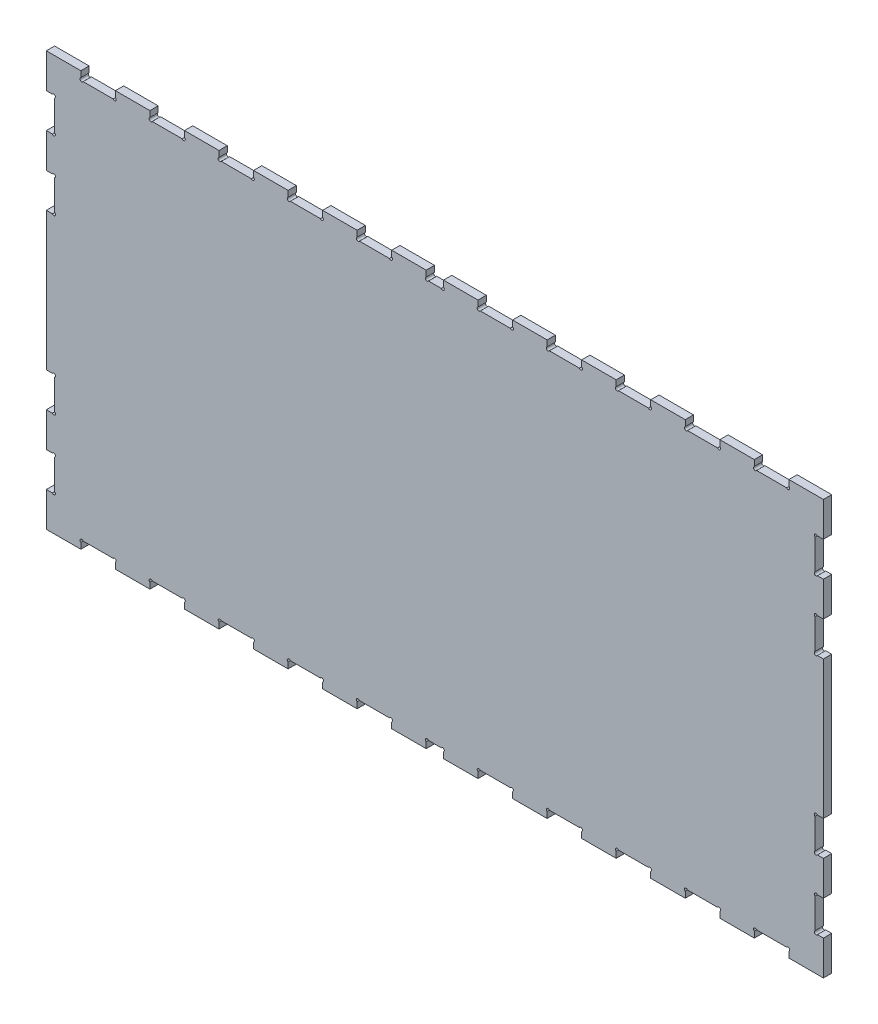
from build123d import *

# Parameters (mm, degrees)
BOSS_EXTRUDE1_DEPTH = 12


with BuildPart() as part:
    # Sketch1 → Boss-Extrude1 (new body)
    with BuildSketch(Plane.XY):
        with BuildLine():
            Line((718.789964832, 153.631186924), (668.789964832, 153.631186924))
            Line((668.789964832, 153.631186924), (668.789964832, 144.909647893))
            ThreePointArc((668.789964832, 144.909647893), (669.287021106, 141.13413065), (665.511503862, 141.631186924))
            Line((665.511503862, 141.631186924), (622.068425801, 141.631186924))
            ThreePointArc((622.068425801, 141.631186924), (618.292908557, 141.13413065), (618.789964832, 144.909647893))
            Line((618.789964832, 144.909647893), (618.789964832, 153.631186924))
            Line((618.789964832, 153.631186924), (568.789964832, 153.631186924))
            Line((568.789964832, 153.631186924), (568.789964832, 144.909647893))
            ThreePointArc((568.789964832, 144.909647893), (569.287021106, 141.13413065), (565.511503862, 141.631186924))
            Line((565.511503862, 141.631186924), (522.068425801, 141.631186924))
            ThreePointArc((522.068425801, 141.631186924), (518.292908557, 141.13413065), (518.789964832, 144.909647893))
            Line((518.789964832, 144.909647893), (518.789964832, 153.631186924))
            Line((518.789964832, 153.631186924), (468.789964832, 153.631186924))
            Line((468.789964832, 153.631186924), (468.789964832, 144.909647893))
            ThreePointArc((468.789964832, 144.909647893), (469.287021106, 141.13413065), (465.511503862, 141.631186924))
            Line((465.511503862, 141.631186924), (422.068425801, 141.631186924))
            ThreePointArc((422.068425801, 141.631186924), (418.292908557, 141.13413065), (418.789964832, 144.909647893))
            Line((418.789964832, 144.909647893), (418.789964832, 153.631186924))
            Line((418.789964832, 153.631186924), (368.789964832, 153.631186924))
            Line((368.789964832, 153.631186924), (368.789964832, 144.909647893))
            ThreePointArc((368.789964832, 144.909647893), (369.287021106, 141.13413065), (365.511503862, 141.631186924))
            Line((365.511503862, 141.631186924), (322.068425801, 141.631186924))
            ThreePointArc((322.068425801, 141.631186924), (318.292908557, 141.13413065), (318.789964832, 144.909647893))
            Line((318.789964832, 144.909647893), (318.789964832, 153.631186924))
            Line((318.789964832, 153.631186924), (268.789964832, 153.631186924))
            Line((268.789964832, 153.631186924), (268.789964832, 144.909647893))
            ThreePointArc((268.789964832, 144.909647893), (269.287021106, 141.13413065), (265.511503862, 141.631186924))
            Line((265.511503862, 141.631186924), (222.068425801, 141.631186924))
            ThreePointArc((222.068425801, 141.631186924), (218.292908557, 141.13413065), (218.789964832, 144.909647893))
            Line((218.789964832, 144.909647893), (218.789964832, 153.631186924))
            Line((218.789964832, 153.631186924), (168.789964832, 153.631186924))
            Line((168.789964832, 153.631186924), (168.789964832, 144.909647893))
            ThreePointArc((168.789964832, 144.909647893), (169.287021106, 141.13413065), (165.511503862, 141.631186924))
            Line((165.511503862, 141.631186924), (147.068425801, 141.631186924))
            ThreePointArc((147.068425801, 141.631186924), (143.292908557, 141.13413065), (143.789964832, 144.909647893))
            Line((143.789964832, 144.909647893), (143.789964832, 153.631186924))
            Line((143.789964832, 153.631186924), (93.789964832, 153.631186924))
            Line((93.789964832, 153.631186924), (93.789964832, 144.909647893))
            ThreePointArc((93.789964832, 144.909647893), (94.287021106, 141.13413065), (90.511503862, 141.631186924))
            Line((90.511503862, 141.631186924), (47.068425801, 141.631186924))
            ThreePointArc((47.068425801, 141.631186924), (43.292908557, 141.13413065), (43.789964832, 144.909647893))
            Line((43.789964832, 144.909647893), (43.789964832, 153.631186924))
            Line((43.789964832, 153.631186924), (-6.210035168, 153.631186924))
            Line((-6.210035168, 153.631186924), (-6.210035168, 144.909647893))
            ThreePointArc((-6.210035168, 144.909647893), (-5.712978894, 141.13413065), (-9.488496138, 141.631186924))
            Line((-9.488496138, 141.631186924), (-52.931574199, 141.631186924))
            ThreePointArc((-52.931574199, 141.631186924), (-56.707091443, 141.13413065), (-56.210035168, 144.909647893))
            Line((-56.210035168, 144.909647893), (-56.210035168, 153.631186924))
            Line((-56.210035168, 153.631186924), (-106.210035168, 153.631186924))
            Line((-106.210035168, 153.631186924), (-106.210035168, 144.909647893))
            ThreePointArc((-106.210035168, 144.909647893), (-105.712978894, 141.13413065), (-109.488496138, 141.631186924))
            Line((-109.488496138, 141.631186924), (-152.931574199, 141.631186924))
            ThreePointArc((-152.931574199, 141.631186924), (-156.707091443, 141.13413065), (-156.210035168, 144.909647893))
            Line((-156.210035168, 144.909647893), (-156.210035168, 153.631186924))
            Line((-156.210035168, 153.631186924), (-206.210035168, 153.631186924))
            Line((-206.210035168, 153.631186924), (-206.210035168, 144.909647893))
            ThreePointArc((-206.210035168, 144.909647893), (-205.712978894, 141.13413065), (-209.488496138, 141.631186924))
            Line((-209.488496138, 141.631186924), (-252.931574199, 141.631186924))
            ThreePointArc((-252.931574199, 141.631186924), (-256.707091443, 141.13413065), (-256.210035168, 144.909647893))
            Line((-256.210035168, 144.909647893), (-256.210035168, 153.631186924))
            Line((-256.210035168, 153.631186924), (-306.210035168, 153.631186924))
            Line((-306.210035168, 153.631186924), (-306.210035168, 144.909647893))
            ThreePointArc((-306.210035168, 144.909647893), (-305.712978894, 141.13413065), (-309.488496138, 141.631186924))
            Line((-309.488496138, 141.631186924), (-352.931574199, 141.631186924))
            ThreePointArc((-352.931574199, 141.631186924), (-356.707091443, 141.13413065), (-356.210035168, 144.909647893))
            Line((-356.210035168, 144.909647893), (-356.210035168, 153.631186924))
            Line((-356.210035168, 153.631186924), (-406.210035168, 153.631186924))
            Line((-406.210035168, 153.631186924), (-406.210035168, 103.631186924))
            Line((-406.210035168, 103.631186924), (-397.488496138, 103.631186924))
            ThreePointArc((-397.488496138, 103.631186924), (-393.712978894, 104.128243199), (-394.210035168, 100.352725955))
            Line((-394.210035168, 100.352725955), (-394.210035168, 56.909647893))
            ThreePointArc((-394.210035168, 56.909647893), (-393.712978894, 53.13413065), (-397.488496138, 53.631186924))
            Line((-397.488496138, 53.631186924), (-406.210035168, 53.631186924))
            Line((-406.210035168, 53.631186924), (-406.210035168, 3.631186924))
            Line((-406.210035168, 3.631186924), (-397.488496138, 3.631186924))
            ThreePointArc((-397.488496138, 3.631186924), (-393.712978894, 4.128243199), (-394.210035168, 0.352725955))
            Line((-394.210035168, 0.352725955), (-394.210035168, -43.090352107))
            ThreePointArc((-394.210035168, -43.090352107), (-393.712978894, -46.86586935), (-397.488496138, -46.368813076))
            Line((-397.488496138, -46.368813076), (-406.210035168, -46.368813076))
            Line((-406.210035168, -46.368813076), (-406.210035168, -246.368813076))
            Line((-406.210035168, -246.368813076), (-397.488496138, -246.368813076))
            ThreePointArc((-397.488496138, -246.368813076), (-393.712978894, -245.871756801), (-394.210035168, -249.647274045))
            Line((-394.210035168, -249.647274045), (-394.210035168, -293.090352107))
            ThreePointArc((-394.210035168, -293.090352107), (-393.712978894, -296.86586935), (-397.488496138, -296.368813076))
            Line((-397.488496138, -296.368813076), (-406.210035168, -296.368813076))
            Line((-406.210035168, -296.368813076), (-406.210035168, -346.368813076))
            Line((-406.210035168, -346.368813076), (-397.488496138, -346.368813076))
            ThreePointArc((-397.488496138, -346.368813076), (-393.712978894, -345.871756801), (-394.210035168, -349.647274045))
            Line((-394.210035168, -349.647274045), (-394.210035168, -393.090352107))
            ThreePointArc((-394.210035168, -393.090352107), (-393.712978894, -396.86586935), (-397.488496138, -396.368813076))
            Line((-397.488496138, -396.368813076), (-406.210035168, -396.368813076))
            Line((-406.210035168, -396.368813076), (-406.210035168, -446.368813076))
            Line((-406.210035168, -446.368813076), (-356.210035168, -446.368813076))
            Line((-356.210035168, -446.368813076), (-356.210035168, -437.647274045))
            ThreePointArc((-356.210035168, -437.647274045), (-356.707091443, -433.871756801), (-352.931574199, -434.368813076))
            Line((-352.931574199, -434.368813076), (-309.488496138, -434.368813076))
            ThreePointArc((-309.488496138, -434.368813076), (-305.712978894, -433.871756801), (-306.210035168, -437.647274045))
            Line((-306.210035168, -437.647274045), (-306.210035168, -446.368813076))
            Line((-306.210035168, -446.368813076), (-256.210035168, -446.368813076))
            Line((-256.210035168, -446.368813076), (-256.210035168, -437.647274045))
            ThreePointArc((-256.210035168, -437.647274045), (-256.707091443, -433.871756801), (-252.931574199, -434.368813076))
            Line((-252.931574199, -434.368813076), (-209.488496138, -434.368813076))
            ThreePointArc((-209.488496138, -434.368813076), (-205.712978894, -433.871756801), (-206.210035168, -437.647274045))
            Line((-206.210035168, -437.647274045), (-206.210035168, -446.368813076))
            Line((-206.210035168, -446.368813076), (-156.210035168, -446.368813076))
            Line((-156.210035168, -446.368813076), (-156.210035168, -437.647274045))
            ThreePointArc((-156.210035168, -437.647274045), (-156.707091443, -433.871756801), (-152.931574199, -434.368813076))
            Line((-152.931574199, -434.368813076), (-109.488496138, -434.368813076))
            ThreePointArc((-109.488496138, -434.368813076), (-105.712978894, -433.871756801), (-106.210035168, -437.647274045))
            Line((-106.210035168, -437.647274045), (-106.210035168, -446.368813076))
            Line((-106.210035168, -446.368813076), (-56.210035168, -446.368813076))
            Line((-56.210035168, -446.368813076), (-56.210035168, -437.647274045))
            ThreePointArc((-56.210035168, -437.647274045), (-56.707091443, -433.871756801), (-52.931574199, -434.368813076))
            Line((-52.931574199, -434.368813076), (-9.488496138, -434.368813076))
            ThreePointArc((-9.488496138, -434.368813076), (-5.712978894, -433.871756801), (-6.210035168, -437.647274045))
            Line((-6.210035168, -437.647274045), (-6.210035168, -446.368813076))
            Line((-6.210035168, -446.368813076), (43.789964832, -446.368813076))
            Line((43.789964832, -446.368813076), (43.789964832, -437.647274045))
            ThreePointArc((43.789964832, -437.647274045), (43.292908557, -433.871756801), (47.068425801, -434.368813076))
            Line((47.068425801, -434.368813076), (90.511503862, -434.368813076))
            ThreePointArc((90.511503862, -434.368813076), (94.287021106, -433.871756801), (93.789964832, -437.647274045))
            Line((93.789964832, -437.647274045), (93.789964832, -446.368813076))
            Line((93.789964832, -446.368813076), (143.789964832, -446.368813076))
            Line((143.789964832, -446.368813076), (143.789964832, -437.647274045))
            ThreePointArc((143.789964832, -437.647274045), (143.292908557, -433.871756801), (147.068425801, -434.368813076))
            Line((147.068425801, -434.368813076), (165.511503862, -434.368813076))
            ThreePointArc((165.511503862, -434.368813076), (169.287021106, -433.871756801), (168.789964832, -437.647274045))
            Line((168.789964832, -437.647274045), (168.789964832, -446.368813076))
            Line((168.789964832, -446.368813076), (218.789964832, -446.368813076))
            Line((218.789964832, -446.368813076), (218.789964832, -437.647274045))
            ThreePointArc((218.789964832, -437.647274045), (218.292908557, -433.871756801), (222.068425801, -434.368813076))
            Line((222.068425801, -434.368813076), (265.511503862, -434.368813076))
            ThreePointArc((265.511503862, -434.368813076), (269.287021106, -433.871756801), (268.789964832, -437.647274045))
            Line((268.789964832, -437.647274045), (268.789964832, -446.368813076))
            Line((268.789964832, -446.368813076), (318.789964832, -446.368813076))
            Line((318.789964832, -446.368813076), (318.789964832, -437.647274045))
            ThreePointArc((318.789964832, -437.647274045), (318.292908557, -433.871756801), (322.068425801, -434.368813076))
            Line((322.068425801, -434.368813076), (365.511503862, -434.368813076))
            ThreePointArc((365.511503862, -434.368813076), (369.287021106, -433.871756801), (368.789964832, -437.647274045))
            Line((368.789964832, -437.647274045), (368.789964832, -446.368813076))
            Line((368.789964832, -446.368813076), (418.789964832, -446.368813076))
            Line((418.789964832, -446.368813076), (418.789964832, -437.647274045))
            ThreePointArc((418.789964832, -437.647274045), (418.292908557, -433.871756801), (422.068425801, -434.368813076))
            Line((422.068425801, -434.368813076), (465.511503862, -434.368813076))
            ThreePointArc((465.511503862, -434.368813076), (469.287021106, -433.871756801), (468.789964832, -437.647274045))
            Line((468.789964832, -437.647274045), (468.789964832, -446.368813076))
            Line((468.789964832, -446.368813076), (518.789964832, -446.368813076))
            Line((518.789964832, -446.368813076), (518.789964832, -437.647274045))
            ThreePointArc((518.789964832, -437.647274045), (518.292908557, -433.871756801), (522.068425801, -434.368813076))
            Line((522.068425801, -434.368813076), (565.511503862, -434.368813076))
            ThreePointArc((565.511503862, -434.368813076), (569.287021106, -433.871756801), (568.789964832, -437.647274045))
            Line((568.789964832, -437.647274045), (568.789964832, -446.368813076))
            Line((568.789964832, -446.368813076), (618.789964832, -446.368813076))
            Line((618.789964832, -446.368813076), (618.789964832, -437.647274045))
            ThreePointArc((618.789964832, -437.647274045), (618.292908557, -433.871756801), (622.068425801, -434.368813076))
            Line((622.068425801, -434.368813076), (665.511503862, -434.368813076))
            ThreePointArc((665.511503862, -434.368813076), (669.287021106, -433.871756801), (668.789964832, -437.647274045))
            Line((668.789964832, -437.647274045), (668.789964832, -446.368813076))
            Line((668.789964832, -446.368813076), (718.789964832, -446.368813076))
            Line((718.789964832, -446.368813076), (718.789964832, -396.368813076))
            Line((718.789964832, -396.368813076), (710.068425801, -396.368813076))
            ThreePointArc((710.068425801, -396.368813076), (706.292908557, -396.86586935), (706.789964832, -393.090352107))
            Line((706.789964832, -393.090352107), (706.789964832, -349.647274045))
            ThreePointArc((706.789964832, -349.647274045), (706.292908557, -345.871756801), (710.068425801, -346.368813076))
            Line((710.068425801, -346.368813076), (718.789964832, -346.368813076))
            Line((718.789964832, -346.368813076), (718.789964832, -296.368813076))
            Line((718.789964832, -296.368813076), (710.068425801, -296.368813076))
            ThreePointArc((710.068425801, -296.368813076), (706.292908557, -296.86586935), (706.789964832, -293.090352107))
            Line((706.789964832, -293.090352107), (706.789964832, -249.647274045))
            ThreePointArc((706.789964832, -249.647274045), (706.292908557, -245.871756801), (710.068425801, -246.368813076))
            Line((710.068425801, -246.368813076), (718.789964832, -246.368813076))
            Line((718.789964832, -246.368813076), (718.789964832, -46.368813076))
            Line((718.789964832, -46.368813076), (710.068425801, -46.368813076))
            ThreePointArc((710.068425801, -46.368813076), (706.292908557, -46.86586935), (706.789964832, -43.090352107))
            Line((706.789964832, -43.090352107), (706.789964832, 0.352725955))
            ThreePointArc((706.789964832, 0.352725955), (706.292908557, 4.128243199), (710.068425801, 3.631186924))
            Line((710.068425801, 3.631186924), (718.789964832, 3.631186924))
            Line((718.789964832, 3.631186924), (718.789964832, 53.631186924))
            Line((718.789964832, 53.631186924), (710.068425801, 53.631186924))
            ThreePointArc((710.068425801, 53.631186924), (706.292908557, 53.13413065), (706.789964832, 56.909647893))
            Line((706.789964832, 56.909647893), (706.789964832, 100.352725955))
            ThreePointArc((706.789964832, 100.352725955), (706.292908557, 104.128243199), (710.068425801, 103.631186924))
            Line((710.068425801, 103.631186924), (718.789964832, 103.631186924))
            Line((718.789964832, 103.631186924), (718.789964832, 153.631186924))
        make_face()
    extrude(amount=BOSS_EXTRUDE1_DEPTH)


solid = part.part
